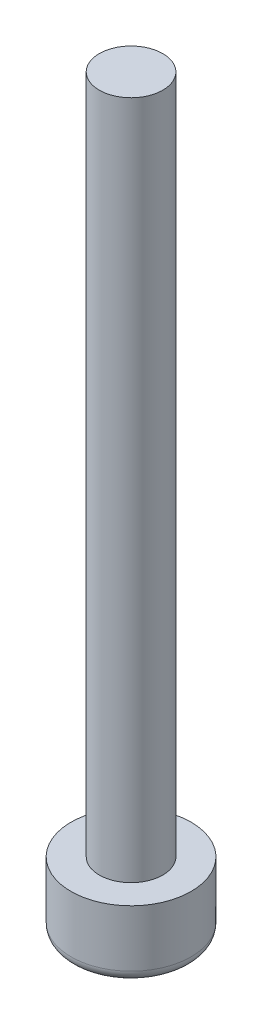
from build123d import *

# Parameters (mm, degrees)
CUT_EXTRUDE1_DEPTH = 2
FILLET1_R          = 0.5


with BuildPart() as part:
    # Sketch2 → Revolve1 (revolve)
    with BuildSketch(Plane.XY):
        Polygon((0, 0), (2.65, 0), (2.65, 3), (1.4, 3), (1.4, 33), (0, 33), align=None)
    revolve(axis=Axis((0, 0, 0), (0, 1, 0)))

    # Sketch3 → Cut-Extrude1 (cut)
    with BuildSketch(Plane.XZ):
        Polygon((-1.443375673, 0), (-0.721687836, -1.25), (0.721687836, -1.25), (1.443375673, 0), (0.721687836, 1.25), (-0.721687836, 1.25), align=None)
    extrude(amount=-CUT_EXTRUDE1_DEPTH, mode=Mode.SUBTRACT)

    # Sketch4 → Cut-Revolve1 (revolve, cut)
    with BuildSketch(Plane(origin=(0, 0, 0), x_dir=(-1, 0, 0), z_dir=(0, 0, -1))):
        with BuildLine():
            Line((0, 0), (0, 0.3))
            ThreePointArc((0, 0.3), (-0.887764045, 0.22445693), (-1.75, 0))
            Line((-1.75, 0), (0, 0))
        make_face()
    revolve(axis=Axis((0, 0, 0), (0, 1, 0)), mode=Mode.SUBTRACT)

    # Fillet1
    fillet1_edges = [part.edges().sort_by_distance(p)[0] for p in [
        (-2.65, 0, 0),
    ]]
    fillet(fillet1_edges, radius=FILLET1_R)


solid = part.part
